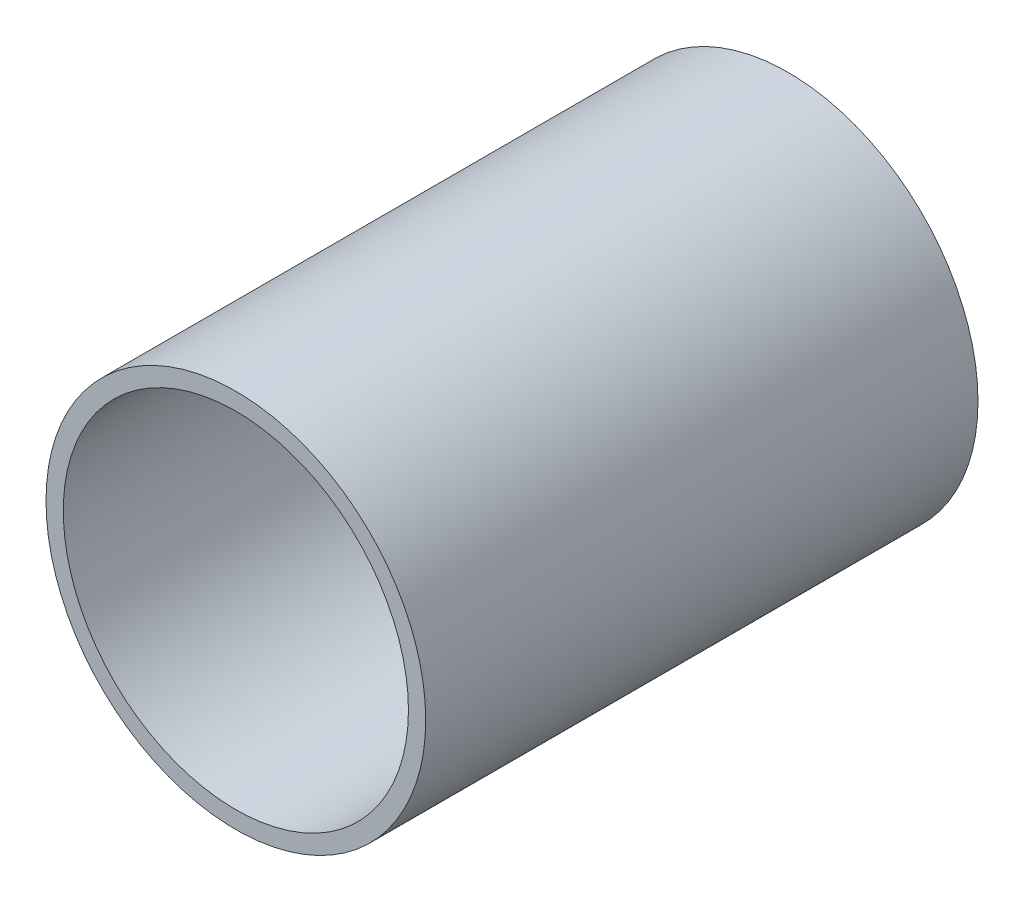
from build123d import *

# Parameters (mm, degrees)
ESQUISSE1_R          = 13.75
ESQUISSE1_R_2        = 12.5
BASE_EXTRUSION_DEPTH = 40


with BuildPart() as part:
    # Esquisse1 → Base-Extrusion (new body)
    with BuildSketch(Plane.XY):
        Circle(ESQUISSE1_R)
        Circle(ESQUISSE1_R_2, mode=Mode.SUBTRACT)
    extrude(amount=BASE_EXTRUSION_DEPTH)


solid = part.part
